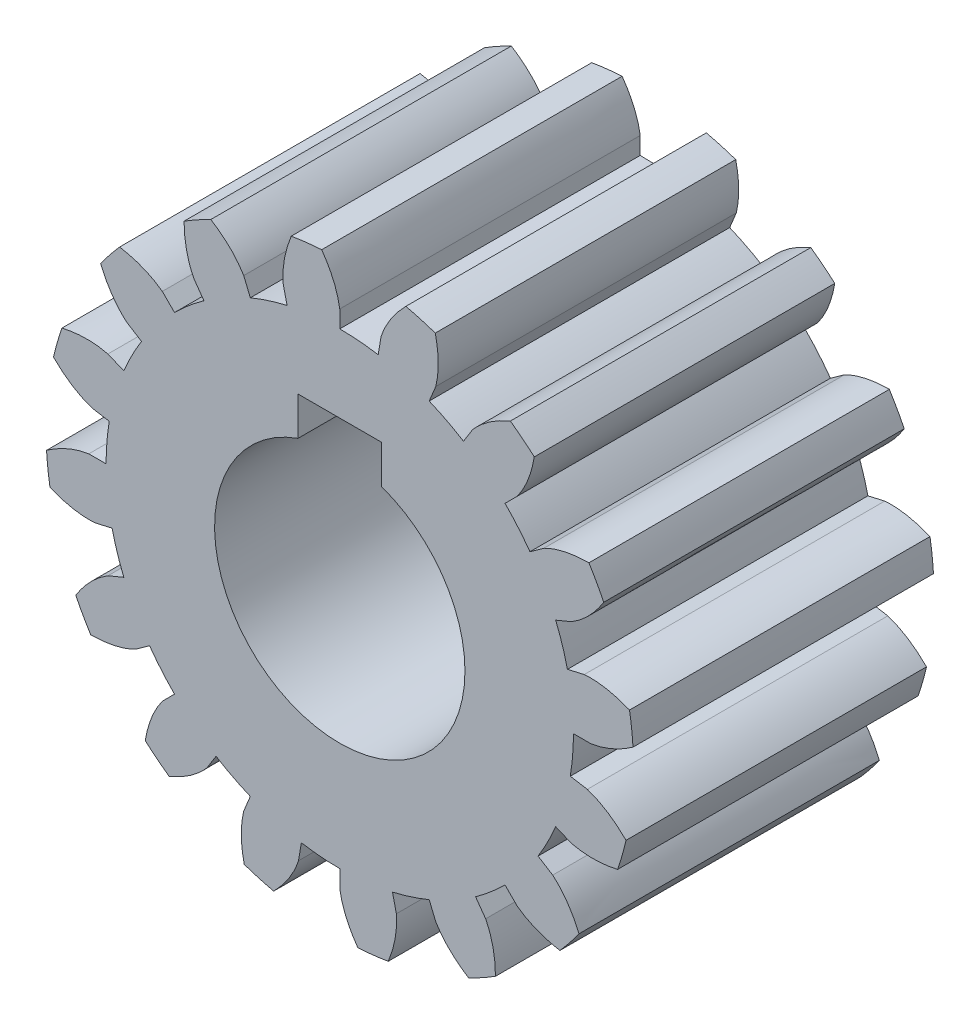
from build123d import *

# Parameters (mm, degrees)
SKETCH2_R           = 14
BOSS_EXTRUDE1_DEPTH = 18
BOSS_EXTRUDE2_DEPTH = 18
SKETCH4_R           = 7.5
CUT_EXTRUDE1_DEPTH  = 19.0000001
SKETCH5_W           = 5
SKETCH5_H           = 2.3
CUT_EXTRUDE2_DEPTH  = 6


with BuildPart() as part:
    # Sketch2 → Boss-Extrude1 (new body)
    with BuildSketch(Plane.XY):
        Circle(SKETCH2_R)
    extrude(amount=BOSS_EXTRUDE1_DEPTH)

    # Sketch3 → Boss-Extrude2 (add, through all)
    with BuildSketch(Plane.XY.offset(18)):
        with BuildLine():
            Line((-3.391023007, 14.647600075), (-3.157587103, 13.639268444))
            ThreePointArc((-3.157587103, 13.639268444), (-1.589062897, 13.909524762), (0, 14))
            Line((0, 14), (0, 15.035))
            add(Edge.make_bspline(
                [(0, 15.035), (-0.142341323, 15.966246749), (-0.546488169, 16.807118385), (-1.083767303, 17.566600366)],
                knots=[0, 0, 0, 0, 0.48587028, 0.48587028, 0.48587028, 0.48587028], degree=3))
            ThreePointArc((-1.083767303, 17.566600366), (-1.997679074, 17.486259701), (-2.90616269, 17.358404835))
            add(Edge.make_bspline(
                [(-3.391023007, 14.647600075), (-3.462384482, 15.586955831), (-3.258302986, 16.497313065), (-2.90616269, 17.358404835)],
                knots=[0, 0, 0, 0, 0.485870285, 0.485870285, 0.485870285, 0.485870285], degree=3))
        make_face()
        with BuildLine():
            Line((5.753645406, 13.890528771), (5.357568053, 12.934313455))
            ThreePointArc((5.357568053, 12.934313455), (3.854841992, 13.458833279), (2.302291967, 13.809397224))
            Line((2.302291967, 13.809397224), (2.472497123, 14.830306233))
            add(Edge.make_bspline(
                [(2.472497123, 14.830306233), (2.766043601, 15.725466644), (3.302968949, 16.488428453), (3.957829715, 17.149215257)],
                knots=[0, 0, 0, 0, 0.485870285, 0.485870285, 0.485870285, 0.485870285], degree=3))
            ThreePointArc((3.957829715, 17.149215257), (4.846087073, 16.919676122), (5.721176494, 16.644162326))
            add(Edge.make_bspline(
                [(5.753645406, 13.890528771), (5.978511873, 14.805360248), (5.926916517, 15.736884645), (5.721176494, 16.644162326)],
                knots=[0, 0, 0, 0, 0.48587028, 0.48587028, 0.48587028, 0.48587028], degree=3))
        make_face()
        with BuildLine():
            Line((10.631350455, 10.631350455), (9.899494937, 9.899494937))
            ThreePointArc((9.899494937, 9.899494937), (8.711882132, 10.959156433), (7.411667955, 11.87717046))
            Line((7.411667955, 11.87717046), (7.959601978, 12.755232705))
            add(Edge.make_bspline(
                [(7.959601978, 12.755232705), (8.57336662, 13.469917712), (9.361393803, 13.969330077), (10.219278424, 14.329213115)],
                knots=[0, 0, 0, 0, 0.485870285, 0.485870285, 0.485870285, 0.485870285], degree=3))
            ThreePointArc((10.219278424, 14.329213115), (10.952080392, 13.777225232), (11.655123032, 13.187801451))
            add(Edge.make_bspline(
                [(10.631350455, 10.631350455), (11.189190832, 11.390491861), (11.498001892, 12.270852873), (11.655123032, 13.187801451)],
                knots=[0, 0, 0, 0, 0.48587028, 0.48587028, 0.48587028, 0.48587028], degree=3))
        make_face()
        with BuildLine():
            Line((13.890528771, 5.753645406), (12.934313455, 5.357568053))
            ThreePointArc((12.934313455, 5.357568053), (12.242617191, 6.791047365), (11.392684683, 8.13675216))
            Line((11.392684683, 8.13675216), (12.234929587, 8.738290623))
            add(Edge.make_bspline(
                [(12.234929587, 8.738290623), (13.075472289, 9.163695914), (13.994631312, 9.323527828), (14.924934631, 9.32771817)],
                knots=[0, 0, 0, 0, 0.485870285, 0.485870285, 0.485870285, 0.485870285], degree=3))
            ThreePointArc((14.924934631, 9.32771817), (15.390718753, 8.53731669), (15.814682743, 7.723717352))
            add(Edge.make_bspline(
                [(13.890528771, 5.753645406), (14.696416916, 6.241524343), (15.318620708, 6.936694986), (15.814682743, 7.723717352)],
                knots=[0, 0, 0, 0, 0.48587028, 0.48587028, 0.48587028, 0.48587028], degree=3))
        make_face()
        with BuildLine():
            Line((15.035, 0), (14, 0))
            ThreePointArc((14, 0), (13.909524762, 1.589062897), (13.639268444, 3.157587103))
            Line((13.639268444, 3.157587103), (14.647600075, 3.391023007))
            add(Edge.make_bspline(
                [(14.647600075, 3.391023007), (15.586955831, 3.462384482), (16.497313065, 3.258302986), (17.358404835, 2.90616269)],
                knots=[0, 0, 0, 0, 0.485870285, 0.485870285, 0.485870285, 0.485870285], degree=3))
            ThreePointArc((17.358404835, 2.90616269), (17.486259701, 1.997679074), (17.566600366, 1.083767303))
            add(Edge.make_bspline(
                [(15.035, 0), (15.966246749, 0.142341323), (16.807118385, 0.546488169), (17.566600366, 1.083767303)],
                knots=[0, 0, 0, 0, 0.48587028, 0.48587028, 0.48587028, 0.48587028], degree=3))
        make_face()
        with BuildLine():
            Line((13.890528771, -5.753645406), (12.934313455, -5.357568053))
            ThreePointArc((12.934313455, -5.357568053), (13.458833279, -3.854841992), (13.809397224, -2.302291967))
            Line((13.809397224, -2.302291967), (14.830306233, -2.472497123))
            add(Edge.make_bspline(
                [(14.830306233, -2.472497123), (15.725466644, -2.766043601), (16.488428453, -3.302968949), (17.149215257, -3.957829715)],
                knots=[0, 0, 0, 0, 0.485870285, 0.485870285, 0.485870285, 0.485870285], degree=3))
            ThreePointArc((17.149215257, -3.957829715), (16.919676122, -4.846087073), (16.644162326, -5.721176494))
            add(Edge.make_bspline(
                [(13.890528771, -5.753645406), (14.805360248, -5.978511873), (15.736884645, -5.926916517), (16.644162326, -5.721176494)],
                knots=[0, 0, 0, 0, 0.48587028, 0.48587028, 0.48587028, 0.48587028], degree=3))
        make_face()
        with BuildLine():
            Line((10.631350455, -10.631350455), (9.899494937, -9.899494937))
            ThreePointArc((9.899494937, -9.899494937), (10.959156433, -8.711882132), (11.87717046, -7.411667955))
            Line((11.87717046, -7.411667955), (12.755232705, -7.959601978))
            add(Edge.make_bspline(
                [(12.755232705, -7.959601978), (13.469917712, -8.57336662), (13.969330077, -9.361393803), (14.329213115, -10.219278424)],
                knots=[0, 0, 0, 0, 0.485870285, 0.485870285, 0.485870285, 0.485870285], degree=3))
            ThreePointArc((14.329213115, -10.219278424), (13.777225232, -10.952080392), (13.187801451, -11.655123032))
            add(Edge.make_bspline(
                [(10.631350455, -10.631350455), (11.390491861, -11.189190832), (12.270852873, -11.498001892), (13.187801451, -11.655123032)],
                knots=[0, 0, 0, 0, 0.48587028, 0.48587028, 0.48587028, 0.48587028], degree=3))
        make_face()
        with BuildLine():
            Line((5.753645406, -13.890528771), (5.357568053, -12.934313455))
            ThreePointArc((5.357568053, -12.934313455), (6.791047365, -12.242617191), (8.13675216, -11.392684683))
            Line((8.13675216, -11.392684683), (8.738290623, -12.234929587))
            add(Edge.make_bspline(
                [(8.738290623, -12.234929587), (9.163695914, -13.075472289), (9.323527828, -13.994631312), (9.32771817, -14.924934631)],
                knots=[0, 0, 0, 0, 0.485870285, 0.485870285, 0.485870285, 0.485870285], degree=3))
            ThreePointArc((9.32771817, -14.924934631), (8.53731669, -15.390718753), (7.723717352, -15.814682743))
            add(Edge.make_bspline(
                [(5.753645406, -13.890528771), (6.241524343, -14.696416916), (6.936694986, -15.318620708), (7.723717352, -15.814682743)],
                knots=[0, 0, 0, 0, 0.48587028, 0.48587028, 0.48587028, 0.48587028], degree=3))
        make_face()
        with BuildLine():
            Line((0, -15.035), (0, -14))
            ThreePointArc((0, -14), (1.589062897, -13.909524762), (3.157587103, -13.639268444))
            Line((3.157587103, -13.639268444), (3.391023007, -14.647600075))
            add(Edge.make_bspline(
                [(3.391023007, -14.647600075), (3.462384482, -15.586955831), (3.258302986, -16.497313065), (2.90616269, -17.358404835)],
                knots=[0, 0, 0, 0, 0.485870285, 0.485870285, 0.485870285, 0.485870285], degree=3))
            ThreePointArc((2.90616269, -17.358404835), (1.997679074, -17.486259701), (1.083767303, -17.566600366))
            add(Edge.make_bspline(
                [(0, -15.035), (0.142341323, -15.966246749), (0.546488169, -16.807118385), (1.083767303, -17.566600366)],
                knots=[0, 0, 0, 0, 0.48587028, 0.48587028, 0.48587028, 0.48587028], degree=3))
        make_face()
        with BuildLine():
            Line((-5.753645406, -13.890528771), (-5.357568053, -12.934313455))
            ThreePointArc((-5.357568053, -12.934313455), (-3.854841992, -13.458833279), (-2.302291967, -13.809397224))
            Line((-2.302291967, -13.809397224), (-2.472497123, -14.830306233))
            add(Edge.make_bspline(
                [(-2.472497123, -14.830306233), (-2.766043601, -15.725466644), (-3.302968949, -16.488428453), (-3.957829715, -17.149215257)],
                knots=[0, 0, 0, 0, 0.485870285, 0.485870285, 0.485870285, 0.485870285], degree=3))
            ThreePointArc((-3.957829715, -17.149215257), (-4.846087073, -16.919676122), (-5.721176494, -16.644162326))
            add(Edge.make_bspline(
                [(-5.753645406, -13.890528771), (-5.978511873, -14.805360248), (-5.926916517, -15.736884645), (-5.721176494, -16.644162326)],
                knots=[0, 0, 0, 0, 0.48587028, 0.48587028, 0.48587028, 0.48587028], degree=3))
        make_face()
        with BuildLine():
            Line((-10.631350455, -10.631350455), (-9.899494937, -9.899494937))
            ThreePointArc((-9.899494937, -9.899494937), (-8.711882132, -10.959156433), (-7.411667955, -11.87717046))
            Line((-7.411667955, -11.87717046), (-7.959601978, -12.755232705))
            add(Edge.make_bspline(
                [(-7.959601978, -12.755232705), (-8.57336662, -13.469917712), (-9.361393803, -13.969330077), (-10.219278424, -14.329213115)],
                knots=[0, 0, 0, 0, 0.485870285, 0.485870285, 0.485870285, 0.485870285], degree=3))
            ThreePointArc((-10.219278424, -14.329213115), (-10.952080392, -13.777225232), (-11.655123032, -13.187801451))
            add(Edge.make_bspline(
                [(-10.631350455, -10.631350455), (-11.189190832, -11.390491861), (-11.498001892, -12.270852873), (-11.655123032, -13.187801451)],
                knots=[0, 0, 0, 0, 0.48587028, 0.48587028, 0.48587028, 0.48587028], degree=3))
        make_face()
        with BuildLine():
            Line((-13.890528771, -5.753645406), (-12.934313455, -5.357568053))
            ThreePointArc((-12.934313455, -5.357568053), (-12.242617191, -6.791047365), (-11.392684683, -8.13675216))
            Line((-11.392684683, -8.13675216), (-12.234929587, -8.738290623))
            add(Edge.make_bspline(
                [(-12.234929587, -8.738290623), (-13.075472289, -9.163695914), (-13.994631312, -9.323527828), (-14.924934631, -9.32771817)],
                knots=[0, 0, 0, 0, 0.485870285, 0.485870285, 0.485870285, 0.485870285], degree=3))
            ThreePointArc((-14.924934631, -9.32771817), (-15.390718753, -8.53731669), (-15.814682743, -7.723717352))
            add(Edge.make_bspline(
                [(-13.890528771, -5.753645406), (-14.696416916, -6.241524343), (-15.318620708, -6.936694986), (-15.814682743, -7.723717352)],
                knots=[0, 0, 0, 0, 0.48587028, 0.48587028, 0.48587028, 0.48587028], degree=3))
        make_face()
        with BuildLine():
            Line((-15.035, 0), (-14, 0))
            ThreePointArc((-14, 0), (-13.909524762, -1.589062897), (-13.639268444, -3.157587103))
            Line((-13.639268444, -3.157587103), (-14.647600075, -3.391023007))
            add(Edge.make_bspline(
                [(-14.647600075, -3.391023007), (-15.586955831, -3.462384482), (-16.497313065, -3.258302986), (-17.358404835, -2.90616269)],
                knots=[0, 0, 0, 0, 0.485870285, 0.485870285, 0.485870285, 0.485870285], degree=3))
            ThreePointArc((-17.358404835, -2.90616269), (-17.486259701, -1.997679074), (-17.566600366, -1.083767303))
            add(Edge.make_bspline(
                [(-15.035, 0), (-15.966246749, -0.142341323), (-16.807118385, -0.546488169), (-17.566600366, -1.083767303)],
                knots=[0, 0, 0, 0, 0.48587028, 0.48587028, 0.48587028, 0.48587028], degree=3))
        make_face()
        with BuildLine():
            Line((-13.890528771, 5.753645406), (-12.934313455, 5.357568053))
            ThreePointArc((-12.934313455, 5.357568053), (-13.458833279, 3.854841992), (-13.809397224, 2.302291967))
            Line((-13.809397224, 2.302291967), (-14.830306233, 2.472497123))
            add(Edge.make_bspline(
                [(-14.830306233, 2.472497123), (-15.725466644, 2.766043601), (-16.488428453, 3.302968949), (-17.149215257, 3.957829715)],
                knots=[0, 0, 0, 0, 0.485870285, 0.485870285, 0.485870285, 0.485870285], degree=3))
            ThreePointArc((-17.149215257, 3.957829715), (-16.919676122, 4.846087073), (-16.644162326, 5.721176494))
            add(Edge.make_bspline(
                [(-13.890528771, 5.753645406), (-14.805360248, 5.978511873), (-15.736884645, 5.926916517), (-16.644162326, 5.721176494)],
                knots=[0, 0, 0, 0, 0.48587028, 0.48587028, 0.48587028, 0.48587028], degree=3))
        make_face()
        with BuildLine():
            Line((-10.631350455, 10.631350455), (-9.899494937, 9.899494937))
            ThreePointArc((-9.899494937, 9.899494937), (-10.959156433, 8.711882132), (-11.87717046, 7.411667955))
            Line((-11.87717046, 7.411667955), (-12.755232705, 7.959601978))
            add(Edge.make_bspline(
                [(-12.755232705, 7.959601978), (-13.469917712, 8.57336662), (-13.969330077, 9.361393803), (-14.329213115, 10.219278424)],
                knots=[0, 0, 0, 0, 0.485870285, 0.485870285, 0.485870285, 0.485870285], degree=3))
            ThreePointArc((-14.329213115, 10.219278424), (-13.777225232, 10.952080392), (-13.187801451, 11.655123032))
            add(Edge.make_bspline(
                [(-10.631350455, 10.631350455), (-11.390491861, 11.189190832), (-12.270852873, 11.498001892), (-13.187801451, 11.655123032)],
                knots=[0, 0, 0, 0, 0.48587028, 0.48587028, 0.48587028, 0.48587028], degree=3))
        make_face()
        with BuildLine():
            Line((-5.753645406, 13.890528771), (-5.357568053, 12.934313455))
            ThreePointArc((-5.357568053, 12.934313455), (-6.791047365, 12.242617191), (-8.13675216, 11.392684683))
            Line((-8.13675216, 11.392684683), (-8.738290623, 12.234929587))
            add(Edge.make_bspline(
                [(-8.738290623, 12.234929587), (-9.163695914, 13.075472289), (-9.323527828, 13.994631312), (-9.32771817, 14.924934631)],
                knots=[0, 0, 0, 0, 0.485870285, 0.485870285, 0.485870285, 0.485870285], degree=3))
            ThreePointArc((-9.32771817, 14.924934631), (-8.53731669, 15.390718753), (-7.723717352, 15.814682743))
            add(Edge.make_bspline(
                [(-5.753645406, 13.890528771), (-6.241524343, 14.696416916), (-6.936694986, 15.318620708), (-7.723717352, 15.814682743)],
                knots=[0, 0, 0, 0, 0.48587028, 0.48587028, 0.48587028, 0.48587028], degree=3))
        make_face()
    extrude(amount=-BOSS_EXTRUDE2_DEPTH)

    # Sketch4 → Cut-Extrude1 (cut, through all)
    with BuildSketch(Plane.XY.offset(18)):
        Circle(SKETCH4_R)
    extrude(amount=-CUT_EXTRUDE1_DEPTH, mode=Mode.SUBTRACT)

    # Sketch5 → Cut-Extrude2 (cut)
    with BuildSketch(Plane.XY.offset(18)):
        with Locations((0, 8.221067812)):
            Rectangle(SKETCH5_W, SKETCH5_H)
    extrude(amount=-CUT_EXTRUDE2_DEPTH, mode=Mode.SUBTRACT)


solid = part.part
